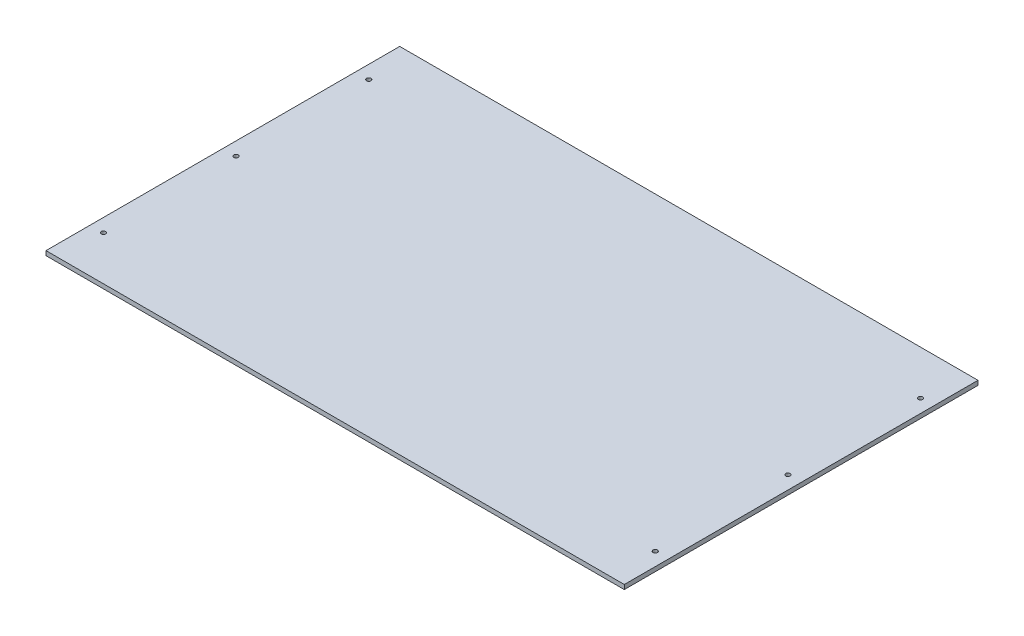
from build123d import *

# Parameters (mm, degrees)
SKETCH1_W           = 654
SKETCH1_H           = 400
BOSS_EXTRUDE1_DEPTH = 5
SKETCH2_R           = 2.5
CUT_EXTRUDE1_DEPTH  = 6


with BuildPart() as part:
    # Sketch1 → Boss-Extrude1 (new body)
    with BuildSketch(Plane(origin=(0, 0, 0), x_dir=(1, 0, 0), z_dir=(0, 1, 0))):
        with Locations((327, 200)):
            Rectangle(SKETCH1_W, SKETCH1_H)
    extrude(amount=BOSS_EXTRUDE1_DEPTH)

    # Sketch2 → Cut-Extrude1 (cut, through all)
    with BuildSketch(Plane(origin=(0, 5, 0), x_dir=(1, 0, 0), z_dir=(0, 1, 0))):
        with Locations((639, 350)):
            Circle(SKETCH2_R)
        with Locations((639, 200)):
            Circle(SKETCH2_R)
        with Locations((639, 50)):
            Circle(SKETCH2_R)
        with Locations((15, 350)):
            Circle(SKETCH2_R)
        with Locations((15, 200)):
            Circle(SKETCH2_R)
        with Locations((15, 50)):
            Circle(SKETCH2_R)
    extrude(amount=-CUT_EXTRUDE1_DEPTH, mode=Mode.SUBTRACT)


solid = part.part
